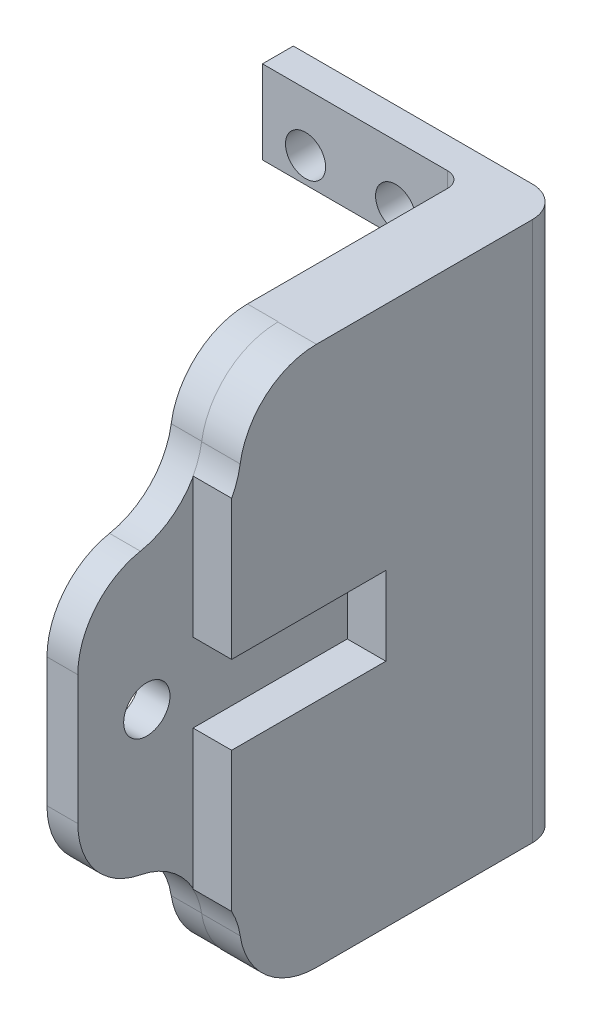
from build123d import *

# Parameters (mm, degrees)
BOSS_EXTRU_1_DEPTH                  = 2.5
ESQUISSE2_W                         = 2.5
ESQUISSE2_H                         = 35
BOSS_EXTRU_2_DEPTH                  = 16
BOSS_EXTRU_3_DEPTH                  = 2
ESQUISSE4_W                         = 2
ESQUISSE4_H                         = 35
BOSS_EXTRU_4_DEPTH                  = 13
ESQUISSE5_W                         = 10
ESQUISSE5_H                         = 5.1
ENL_V_MAT_EXTRU_1_DEPTH             = 2.5
ESQUISSE6_W                         = 11.43
ESQUISSE6_H                         = 24.2
ENL_V_MAT_EXTRU_2_DEPTH             = 3
DIAM_TRE_DU_PER_AGE_2_6_2_6_1_D     = 2.6
DIAM_TRE_DU_PER_AGE_2_6_2_6_1_DEPTH = 28.974295462
DIAM_TRE_DU_PER_AGE_3_0_3_1_D       = 3
DIAM_TRE_DU_PER_AGE_3_0_3_1_DEPTH   = 4.5
CONG_1_R                            = 1
CONG_2_R                            = 2


with BuildPart() as part:
    # Esquisse1 → Boss.-Extru.1 (new body)
    with BuildSketch(Plane(origin=(17.5, 0, 0), x_dir=(0, 0, -1), z_dir=(1, 0, 0))):
        with BuildLine():
            Line((-7, 0), (-7, 35))
            ThreePointArc((-7, 35), (-10.259601203, 33.791437722), (-11.943429983, 30.75))
            ThreePointArc((-11.943429983, 30.75), (-12.14941104, 29.901069836), (-12.5, 29.100946096))
            Line((-12.5, 29.100946096), (-12.5, 5.899053904))
            ThreePointArc((-12.5, 5.899053904), (-12.14941104, 5.098930164), (-11.943429983, 4.25))
            ThreePointArc((-11.943429983, 4.25), (-10.259601203, 1.208562278), (-7, 0))
        make_face()
    extrude(amount=-BOSS_EXTRU_1_DEPTH)

    # Esquisse2 → Boss.-Extru.2 (add)
    with BuildSketch(Plane(origin=(0, 0, 7), x_dir=(-1, 0, 0), z_dir=(0, 0, -1))):
        with Locations((-16.25, 17.5)):
            Rectangle(ESQUISSE2_W, ESQUISSE2_H)
    extrude(amount=BOSS_EXTRU_2_DEPTH)

    # Esquisse3 → Boss.-Extru.3 (add)
    with BuildSketch(Plane.ZY.offset(-15)):
        with BuildLine():
            Line((19.974295462, 21.679625289), (19.974295462, 13.320374711))
            ThreePointArc((19.974295462, 13.320374711), (18.828977674, 10.135814295), (15.917725445, 8.410187356))
            ThreePointArc((15.917725445, 8.410187356), (13.256912127, 6.965462484), (11.917725445, 4.25))
            ThreePointArc((11.917725445, 4.25), (10.233896665, 1.208562278), (6.974295462, 0))
            Line((6.974295462, 0), (-9, 0))
            Line((-9, 0), (-9, 35))
            Line((-9, 35), (6.974295462, 35))
            ThreePointArc((6.974295462, 35), (10.233896665, 33.791437722), (11.917725445, 30.75))
            ThreePointArc((11.917725445, 30.75), (13.256912127, 28.034537516), (15.917725445, 26.589812644))
            ThreePointArc((15.917725445, 26.589812644), (18.828977674, 24.864185705), (19.974295462, 21.679625289))
        make_face()
    extrude(amount=BOSS_EXTRU_3_DEPTH)

    # Esquisse4 → Boss.-Extru.4 (add)
    with BuildSketch(Plane.ZY.offset(-13)):
        with Locations((-8, 17.5)):
            Rectangle(ESQUISSE4_W, ESQUISSE4_H)
    extrude(amount=BOSS_EXTRU_4_DEPTH)

    # Esquisse5 → Enlèv. mat.-Extru.1 (cut)
    with BuildSketch(Plane(origin=(17.5, 0, 0), x_dir=(0, 0, -1), z_dir=(1, 0, 0))):
        with Locations((-7.5, 17.5)):
            Rectangle(ESQUISSE5_W, ESQUISSE5_H)
    extrude(amount=-ENL_V_MAT_EXTRU_1_DEPTH, mode=Mode.SUBTRACT)

    # Esquisse6 → Enlèv. mat.-Extru.2 (cut, through all)
    with BuildSketch(Plane.XY.offset(-7)):
        with Locations((5.715, 17.5)):
            Rectangle(ESQUISSE6_W, ESQUISSE6_H)
    extrude(amount=-ENL_V_MAT_EXTRU_2_DEPTH, mode=Mode.SUBTRACT)

    # Diamètre du perçage Ø2.6 (2.6)1
    with Locations(Plane(origin=(0, 0, -9), x_dir=(-1, 0, 0), z_dir=(0, 0, -1))):
        with Locations((-8.593600322, 3.75), (-8.636, 31.25), (-2.794, 31.25), (-2.836399678, 3.75)):
            Hole(DIAM_TRE_DU_PER_AGE_2_6_2_6_1_D / 2, depth=DIAM_TRE_DU_PER_AGE_2_6_2_6_1_DEPTH)

    # Diamètre du perçage Ø3.0 (3)1
    with Locations(Plane.ZY.offset(-13)):
        with Locations((15.5, 17.5)):
            Hole(DIAM_TRE_DU_PER_AGE_3_0_3_1_D / 2, depth=DIAM_TRE_DU_PER_AGE_3_0_3_1_DEPTH)

    # Congé1
    cong_1_edges = [part.edges().sort_by_distance(p)[0] for p in [
        (13, 17.5, -7),
    ]]
    fillet(cong_1_edges, radius=CONG_1_R)

    # Congé2
    cong_2_edges = [part.edges().sort_by_distance(p)[0] for p in [
        (17.5, 17.5, -9),
    ]]
    fillet(cong_2_edges, radius=CONG_2_R)


solid = part.part
